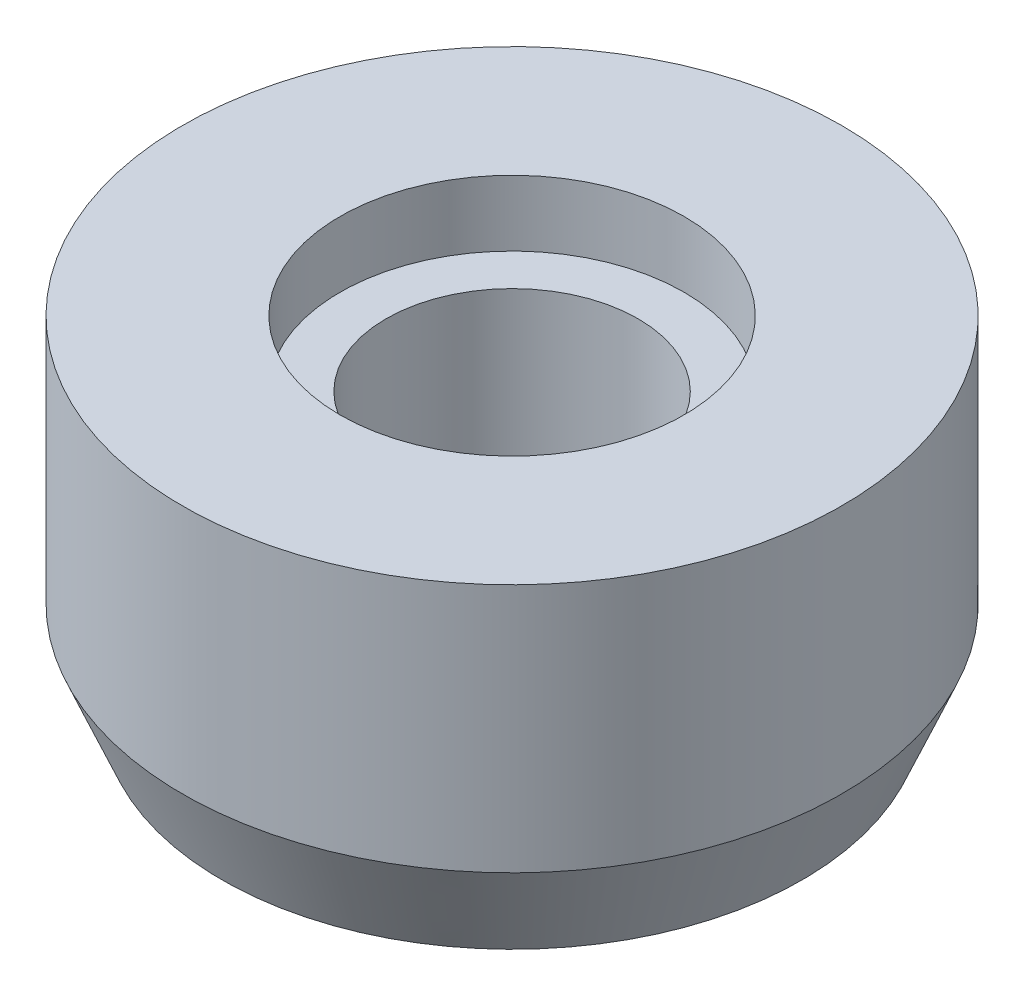
from build123d import *


with BuildPart() as part:
    # Sketch1 → Revolve1 (revolve)
    with BuildSketch(Plane.XY):
        Polygon((4.8, 0), (11.05, 0), (12.55, 3.582608696), (12.55, 13.082608696), (6.55, 13.082608696), (6.55, 10.582608696), (4.8, 10.582608696), align=None)
    revolve(axis=Axis((0, 0, 0), (0, 1, 0)))


solid = part.part
